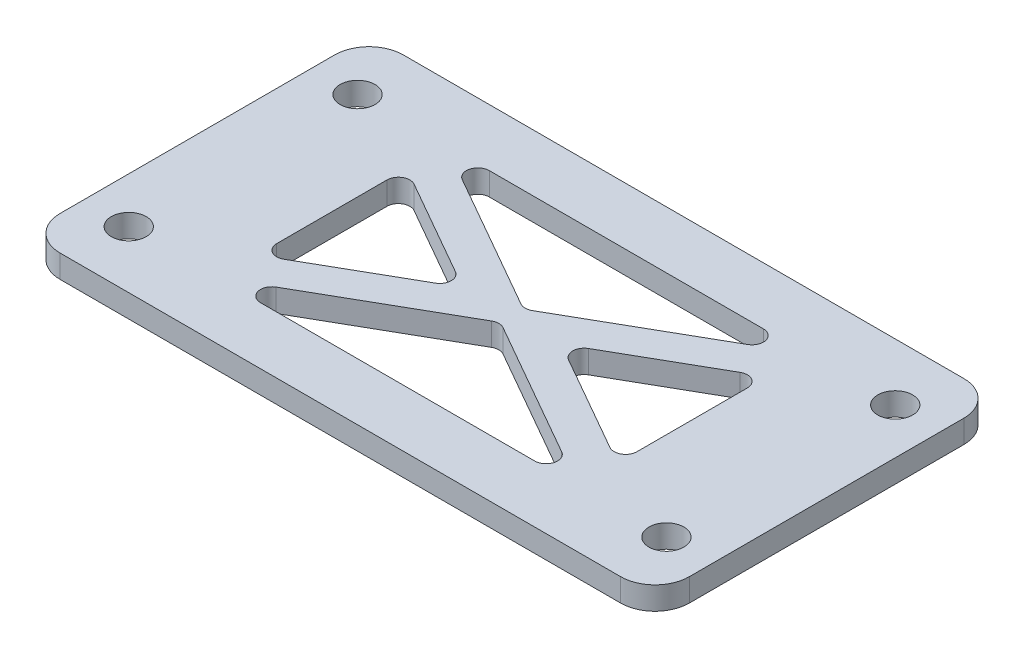
from build123d import *

# Parameters (mm, degrees)
SKETCH_1_W          = 55
SKETCH_1_H          = 30
EXTRUDE_1_DEPTH     = 2
SKETCH_2_R          = 1.525
CUT_EXTRUDE_1_DEPTH = 2
FILLET_1_R          = 3
CUT_EXTRUDE_2_DEPTH = 2
FILLET_2_R          = 1


with BuildPart() as part:
    # 草图1 → 凸台-拉伸1 (new body)
    with BuildSketch(Plane(origin=(0, 0, 0), x_dir=(1, 0, 0), z_dir=(0, 1, 0))):
        Rectangle(SKETCH_1_W, SKETCH_1_H)
    extrude(amount=EXTRUDE_1_DEPTH)

    # 草图2 → 切除-拉伸1 (cut)
    with BuildSketch(Plane(origin=(0, 2, 0), x_dir=(1, 0, 0), z_dir=(0, 1, 0))):
        with Locations((-23.5, 10)):
            Circle(SKETCH_2_R)
        with Locations((-23.5, -10)):
            Circle(SKETCH_2_R)
        with Locations((23.5, -10)):
            Circle(SKETCH_2_R)
        with Locations((23.5, 10)):
            Circle(SKETCH_2_R)
    extrude(amount=-CUT_EXTRUDE_1_DEPTH, mode=Mode.SUBTRACT)

    # 圆角1
    fillet_1_edges = [part.edges().sort_by_distance(p)[0] for p in [
        (27.5, 1, 15),
        (-27.5, 1, 15),
        (-27.5, 1, -15),
        (27.5, 1, -15),
    ]]
    fillet(fillet_1_edges, radius=FILLET_1_R)

    # 草图3 → 切除-拉伸2 (cut)
    with BuildSketch(Plane(origin=(0, 2, 0), x_dir=(1, 0, 0), z_dir=(0, 1, 0))):
        Polygon((-15.75, 10), (15.75, 10), (0, 1), align=None)
        Polygon((-15.75, 6.544746679), (-15.75, -6.544746679), (-4.296693311, 0), align=None)
        Polygon((-15.75, -10), (15.75, -10), (0, -1), align=None)
        Polygon((15.75, 6.544746679), (15.75, -6.544746679), (4.296693311, 0), align=None)
    extrude(amount=-CUT_EXTRUDE_2_DEPTH, mode=Mode.SUBTRACT)

    # 圆角2
    fillet_2_edges = [part.edges().sort_by_distance(p)[0] for p in [
        (15.75, 1, 10),
        (0, 1, 1),
        (-15.75, 1, 10),
        (-15.75, 1, 6.544746679),
        (-4.296693311, 1, 0),
        (-15.75, 1, -6.544746679),
        (15.75, 1, 6.544746679),
        (15.75, 1, -6.544746679),
        (4.296693311, 1, 0),
        (15.75, 1, -10),
        (-15.75, 1, -10),
        (0, 1, -1),
    ]]
    fillet(fillet_2_edges, radius=FILLET_2_R)


solid = part.part
